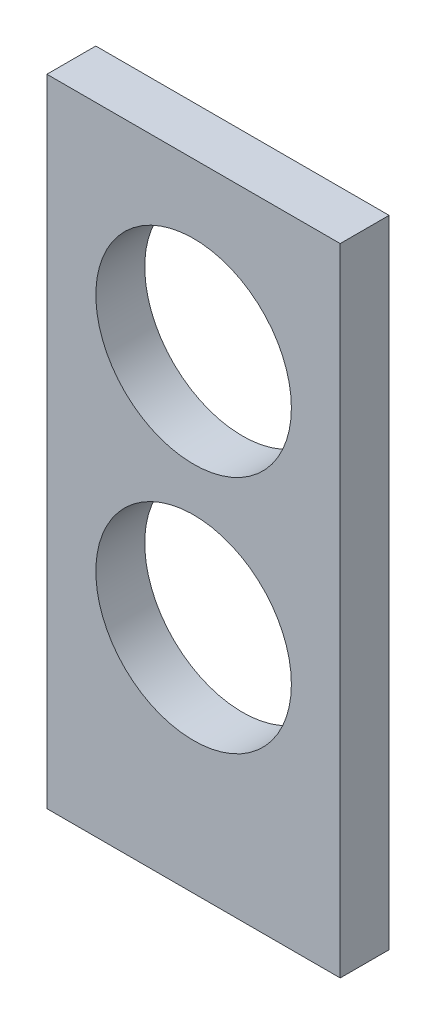
from build123d import *

# Parameters (mm, degrees)
SKETCH1_W           = 30
SKETCH1_H           = 65.056292468
SKETCH1_R           = 10
BOSS_EXTRUDE1_DEPTH = 5


with BuildPart() as part:
    # Sketch1 → Boss-Extrude1 (new body)
    with BuildSketch(Plane.XY):
        with Locations((-0.005493168, -8.057986772)):
            Rectangle(SKETCH1_W, SKETCH1_H)
        with Locations((0, 7.422751964)):
            Circle(SKETCH1_R, mode=Mode.SUBTRACT)
        with Locations((0, -17.054465918)):
            Circle(SKETCH1_R, mode=Mode.SUBTRACT)
    extrude(amount=BOSS_EXTRUDE1_DEPTH)


solid = part.part
